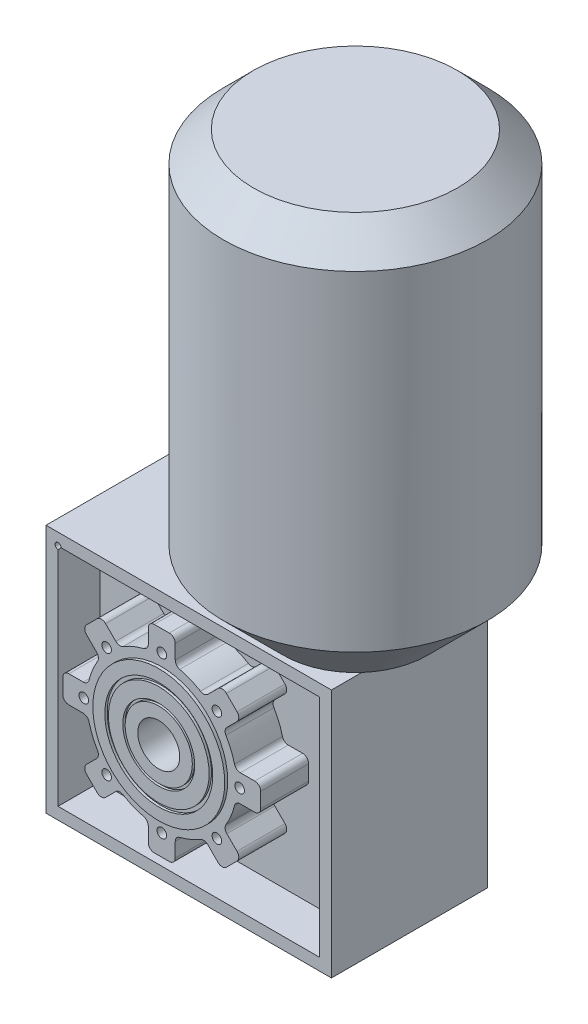
from build123d import *

# Parameters (mm, degrees)
SKETCH1_W                = 238
SKETCH1_H                = 208
SKETCH1_R                = 17.5
SKETCH1_R_2              = 2.5
BOSS_EXTRUDE1_DEPTH      = 130
SKETCH4_W                = 218
SKETCH4_H                = 188
SKETCH4_R                = 62.5
CUT_EXTRUDE1_DEPTH       = 35
CUT_EXTRUDE2_START       = -46
SKETCH5_W                = 218
SKETCH5_H                = 188
SKETCH5_R                = 62.5
CUT_EXTRUDE2_DEPTH       = 46
BOSS_EXTRUDE2_DEPTH      = 35
SKETCH7_R                = 4
CUT_EXTRUDE3_DEPTH       = 20
FILLET1_R                = 5
CIRPATTERN1_COUNT        = 8
FILLET1_OF_CIRPATTERN1_R = 5
BOSS_EXTRUDE3_START      = 5
SKETCH8_R                = 4
SKETCH8_R_2              = 17.5
BOSS_EXTRUDE3_DEPTH      = 5
BOSS_EXTRUDE5_START      = 2.5
SKETCH9_R                = 55
SKETCH9_R_2              = 17.5
BOSS_EXTRUDE5_DEPTH      = 2.5
SKETCH10_R               = 45
SKETCH10_R_2             = 42
CUT_EXTRUDE4_DEPTH       = 2
SKETCH11_R               = 30
SKETCH11_R_2             = 28
CUT_EXTRUDE5_DEPTH       = 2


with BuildPart() as part:
    # Sketch1 → Boss-Extrude1 (new body)
    with BuildSketch(Plane.XY):
        with Locations((154, 104)):
            Rectangle(SKETCH1_W, SKETCH1_H)
        with Locations((136.5, 104)):
            Circle(SKETCH1_R, mode=Mode.SUBTRACT)
        with Locations((45, 198)):
            Circle(SKETCH1_R_2, mode=Mode.SUBTRACT)
    extrude(amount=-BOSS_EXTRUDE1_DEPTH)

    # Sketch2 → Revolve1 (revolve)
    with BuildSketch(Plane.XY.offset(-65), mode=Mode.PRIVATE) as revolve1_sk:
        Polygon((288, 208), (338, 258), (338, 533), (313, 558), (228, 558), (228, 208), align=None)
    revolve(revolve1_sk.sketch.rotate(Axis((228, 157.831191951, -65), (0, 1, 0)), 90), axis=Axis((228, 157.831191951, -65), (0, 1, 0)))

    # Sketch4 → Cut-Extrude1 (cut)
    with BuildSketch(Plane.XY):
        with Locations((154, 104)):
            Rectangle(SKETCH4_W, SKETCH4_H)
        with Locations((136.5, 104)):
            Circle(SKETCH4_R, mode=Mode.SUBTRACT)
    extrude(amount=-CUT_EXTRUDE1_DEPTH, mode=Mode.SUBTRACT)

    # Sketch5 → Cut-Extrude2 (cut)
    with BuildSketch(Plane(origin=(0, 0, -130), x_dir=(-1, 0, 0), z_dir=(0, 0, -1)).offset(CUT_EXTRUDE2_START)):
        with Locations((-154, 104)):
            Rectangle(SKETCH5_W, SKETCH5_H)
        with Locations(Location((-136.5, 104, 0), (0, 0, 180))):
            Circle(SKETCH5_R, mode=Mode.SUBTRACT)
    extrude(amount=CUT_EXTRUDE2_DEPTH, mode=Mode.SUBTRACT)

    # Sketch6 → Boss-Extrude2 (add)
    with BuildSketch(Plane.XY):
        with BuildLine():
            Line((125.25, 165.479163137), (125.25, 186.5))
            Line((125.25, 186.5), (147.75, 186.5))
            Line((147.75, 186.5), (147.75, 165.479163137))
            ThreePointArc((147.75, 165.479163137), (136.5, 166.5), (125.25, 165.479163137))
        make_face()
    boss_extrude2 = extrude(amount=-BOSS_EXTRUDE2_DEPTH)

    # Sketch7 → Cut-Extrude3 (cut)
    with BuildSketch(Plane.XY):
        with Locations((136.5, 169)):
            Circle(SKETCH7_R)
    cut_extrude3 = extrude(amount=-CUT_EXTRUDE3_DEPTH, mode=Mode.SUBTRACT)

    # Fillet1
    fillet1_edges = [part.edges().sort_by_distance(p)[0] for p in [
        (147.75, 165.479163137, -17.5),
        (125.25, 165.479163137, -17.5),
        (125.25, 186.5, -17.5),
        (147.75, 186.5, -17.5),
    ]]
    fillet(fillet1_edges, radius=FILLET1_R)

    # CirPattern1: Boss-Extrude2, Cut-Extrude3 ×8 about axis
    cirpattern1_axis = Axis((136.5, 104, 0), (0, 0, 1))
    add([boss_extrude2.rotate(cirpattern1_axis, i * 360 / CIRPATTERN1_COUNT) for i in range(1, CIRPATTERN1_COUNT)])
    add([cut_extrude3.rotate(cirpattern1_axis, i * 360 / CIRPATTERN1_COUNT) for i in range(1, CIRPATTERN1_COUNT)], mode=Mode.SUBTRACT)

    # Fillet1 of CirPattern1
    fillet1_of_cirpattern1_edges = [part.edges().sort_by_distance(p)[0] for p in [
        (100.982618133, 155.427284444, -17.5),
        (85.072715556, 139.517381867, -17.5),
        (70.208739264, 154.38135816, -17.5),
        (86.11864184, 170.291260736, -17.5),
        (75.020836863, 115.25, -17.5),
        (75.020836863, 92.75, -17.5),
        (54, 92.75, -17.5),
        (54, 115.25, -17.5),
        (85.072715556, 68.482618133, -17.5),
        (100.982618133, 52.572715556, -17.5),
        (86.11864184, 37.708739264, -17.5),
        (70.208739264, 53.61864184, -17.5),
        (125.25, 42.520836863, -17.5),
        (147.75, 42.520836863, -17.5),
        (147.75, 21.5, -17.5),
        (125.25, 21.5, -17.5),
        (172.017381867, 52.572715556, -17.5),
        (187.927284444, 68.482618133, -17.5),
        (202.791260736, 53.61864184, -17.5),
        (186.88135816, 37.708739264, -17.5),
        (197.979163137, 92.75, -17.5),
        (197.979163137, 115.25, -17.5),
        (219, 115.25, -17.5),
        (219, 92.75, -17.5),
        (187.927284444, 139.517381867, -17.5),
        (172.017381867, 155.427284444, -17.5),
        (186.88135816, 170.291260736, -17.5),
        (202.791260736, 154.38135816, -17.5),
    ]]
    fillet(fillet1_of_cirpattern1_edges, radius=FILLET1_OF_CIRPATTERN1_R)

    # Sketch8 → Boss-Extrude3 (add)
    with BuildSketch(Plane.XY.offset(BOSS_EXTRUDE3_START)):
        with BuildLine():
            Line((98.129000138, 158.280902439), (89.654175746, 166.75572683))
            ThreePointArc((89.654175746, 166.75572683), (86.11864184, 168.220192924), (82.583107935, 166.75572683))
            Line((82.583107935, 166.75572683), (73.74427317, 157.916892065))
            ThreePointArc((73.74427317, 157.916892065), (72.279807076, 154.38135816), (73.74427317, 150.845824254))
            Line((73.74427317, 150.845824254), (82.219097561, 142.370999862))
            ThreePointArc((82.219097561, 142.370999862), (83.646664321, 139.441792417), (82.966262644, 136.255061071))
            ThreePointArc((82.966262644, 136.255061071), (78.757529218, 127.917714523), (75.838158883, 119.046296296))
            ThreePointArc((75.838158883, 119.046296296), (74.065916178, 116.311820311), (70.985211593, 115.25))
            Line((70.985211593, 115.25), (59, 115.25))
            ThreePointArc((59, 115.25), (55.464466094, 113.785533906), (54, 110.25))
            Line((54, 110.25), (54, 97.75))
            ThreePointArc((54, 97.75), (55.464466094, 94.214466094), (59, 92.75))
            Line((59, 92.75), (70.985211593, 92.75))
            ThreePointArc((70.985211593, 92.75), (74.065916178, 91.688179689), (75.838158883, 88.953703704))
            ThreePointArc((75.838158883, 88.953703704), (78.757529218, 80.082285477), (82.966262644, 71.744938929))
            ThreePointArc((82.966262644, 71.744938929), (83.646664321, 68.558207583), (82.219097561, 65.629000138))
            Line((82.219097561, 65.629000138), (73.74427317, 57.154175746))
            ThreePointArc((73.74427317, 57.154175746), (72.279807076, 53.61864184), (73.74427317, 50.083107935))
            Line((73.74427317, 50.083107935), (82.583107935, 41.24427317))
            ThreePointArc((82.583107935, 41.24427317), (86.11864184, 39.779807076), (89.654175746, 41.24427317))
            Line((89.654175746, 41.24427317), (98.129000138, 49.719097561))
            ThreePointArc((98.129000138, 49.719097561), (101.058207583, 51.146664321), (104.244938929, 50.466262644))
            ThreePointArc((104.244938929, 50.466262644), (112.582285477, 46.257529218), (121.453703704, 43.338158883))
            ThreePointArc((121.453703704, 43.338158883), (124.188179689, 41.565916178), (125.25, 38.485211593))
            Line((125.25, 38.485211593), (125.25, 26.5))
            ThreePointArc((125.25, 26.5), (126.714466094, 22.964466094), (130.25, 21.5))
            Line((130.25, 21.5), (142.75, 21.5))
            ThreePointArc((142.75, 21.5), (146.285533906, 22.964466094), (147.75, 26.5))
            Line((147.75, 26.5), (147.75, 38.485211593))
            ThreePointArc((147.75, 38.485211593), (148.811820311, 41.565916178), (151.546296296, 43.338158883))
            ThreePointArc((151.546296296, 43.338158883), (160.417714523, 46.257529218), (168.755061071, 50.466262644))
            ThreePointArc((168.755061071, 50.466262644), (171.941792417, 51.146664321), (174.870999862, 49.719097561))
            Line((174.870999862, 49.719097561), (183.345824254, 41.24427317))
            ThreePointArc((183.345824254, 41.24427317), (186.88135816, 39.779807076), (190.416892065, 41.24427317))
            Line((190.416892065, 41.24427317), (199.25572683, 50.083107935))
            ThreePointArc((199.25572683, 50.083107935), (200.720192924, 53.61864184), (199.25572683, 57.154175746))
            Line((199.25572683, 57.154175746), (190.780902439, 65.629000138))
            ThreePointArc((190.780902439, 65.629000138), (189.353335679, 68.558207583), (190.033737356, 71.744938929))
            ThreePointArc((190.033737356, 71.744938929), (194.242470782, 80.082285477), (197.161841117, 88.953703704))
            ThreePointArc((197.161841117, 88.953703704), (198.934083822, 91.688179689), (202.014788407, 92.75))
            Line((202.014788407, 92.75), (214, 92.75))
            ThreePointArc((214, 92.75), (217.535533906, 94.214466094), (219, 97.75))
            Line((219, 97.75), (219, 110.25))
            ThreePointArc((219, 110.25), (217.535533906, 113.785533906), (214, 115.25))
            Line((214, 115.25), (202.014788407, 115.25))
            ThreePointArc((202.014788407, 115.25), (198.934083822, 116.311820311), (197.161841117, 119.046296296))
            ThreePointArc((197.161841117, 119.046296296), (194.242470782, 127.917714523), (190.033737356, 136.255061071))
            ThreePointArc((190.033737356, 136.255061071), (189.353335679, 139.441792417), (190.780902439, 142.370999862))
            Line((190.780902439, 142.370999862), (199.25572683, 150.845824254))
            ThreePointArc((199.25572683, 150.845824254), (200.720192924, 154.38135816), (199.25572683, 157.916892065))
            Line((199.25572683, 157.916892065), (190.416892065, 166.75572683))
            ThreePointArc((190.416892065, 166.75572683), (186.88135816, 168.220192924), (183.345824254, 166.75572683))
            Line((183.345824254, 166.75572683), (174.870999862, 158.280902439))
            ThreePointArc((174.870999862, 158.280902439), (171.941792417, 156.853335679), (168.755061071, 157.533737356))
            ThreePointArc((168.755061071, 157.533737356), (160.417714523, 161.742470782), (151.546296296, 164.661841117))
            ThreePointArc((151.546296296, 164.661841117), (148.811820311, 166.434083822), (147.75, 169.514788407))
            Line((147.75, 169.514788407), (147.75, 181.5))
            ThreePointArc((147.75, 181.5), (146.285533906, 185.035533906), (142.75, 186.5))
            Line((142.75, 186.5), (130.25, 186.5))
            ThreePointArc((130.25, 186.5), (126.714466094, 185.035533906), (125.25, 181.5))
            Line((125.25, 181.5), (125.25, 169.514788407))
            ThreePointArc((125.25, 169.514788407), (124.188179689, 166.434083822), (121.453703704, 164.661841117))
            ThreePointArc((121.453703704, 164.661841117), (112.582285477, 161.742470782), (104.244938929, 157.533737356))
            ThreePointArc((104.244938929, 157.533737356), (101.058207583, 156.853335679), (98.129000138, 158.280902439))
        make_face()
        with Locations((182.461940777, 58.038059223)):
            Circle(SKETCH8_R, mode=Mode.SUBTRACT)
        with Locations((136.5, 39)):
            Circle(SKETCH8_R, mode=Mode.SUBTRACT)
        with Locations((90.538059223, 58.038059223)):
            Circle(SKETCH8_R, mode=Mode.SUBTRACT)
        with Locations((71.5, 104)):
            Circle(SKETCH8_R, mode=Mode.SUBTRACT)
        with Locations((201.5, 104)):
            Circle(SKETCH8_R, mode=Mode.SUBTRACT)
        with Locations((182.461940777, 149.961940777)):
            Circle(SKETCH8_R, mode=Mode.SUBTRACT)
        with Locations((136.5, 104)):
            Circle(SKETCH8_R_2, mode=Mode.SUBTRACT)
        with Locations((90.538059223, 149.961940777)):
            Circle(SKETCH8_R, mode=Mode.SUBTRACT)
        with Locations((136.5, 169)):
            Circle(SKETCH8_R, mode=Mode.SUBTRACT)
    extrude(amount=-BOSS_EXTRUDE3_DEPTH)

    # Sketch9 → Boss-Extrude5 (add)
    with BuildSketch(Plane.XY.offset(5).offset(BOSS_EXTRUDE5_START)):
        with Locations((136.5, 104)):
            Circle(SKETCH9_R)
        with Locations((136.5, 104)):
            Circle(SKETCH9_R_2, mode=Mode.SUBTRACT)
    extrude(amount=-BOSS_EXTRUDE5_DEPTH)

    # Sketch10 → Cut-Extrude4 (cut)
    with BuildSketch(Plane.XY.offset(7.5)):
        with Locations((136.5, 104)):
            Circle(SKETCH10_R)
        with Locations((136.5, 104)):
            Circle(SKETCH10_R_2, mode=Mode.SUBTRACT)
    extrude(amount=-CUT_EXTRUDE4_DEPTH, mode=Mode.SUBTRACT)

    # Sketch11 → Cut-Extrude5 (cut)
    with BuildSketch(Plane.XY.offset(7.5)):
        with Locations((136.5, 104)):
            Circle(SKETCH11_R)
        with Locations((136.5, 104)):
            Circle(SKETCH11_R_2, mode=Mode.SUBTRACT)
    extrude(amount=-CUT_EXTRUDE5_DEPTH, mode=Mode.SUBTRACT)


solid = part.part
